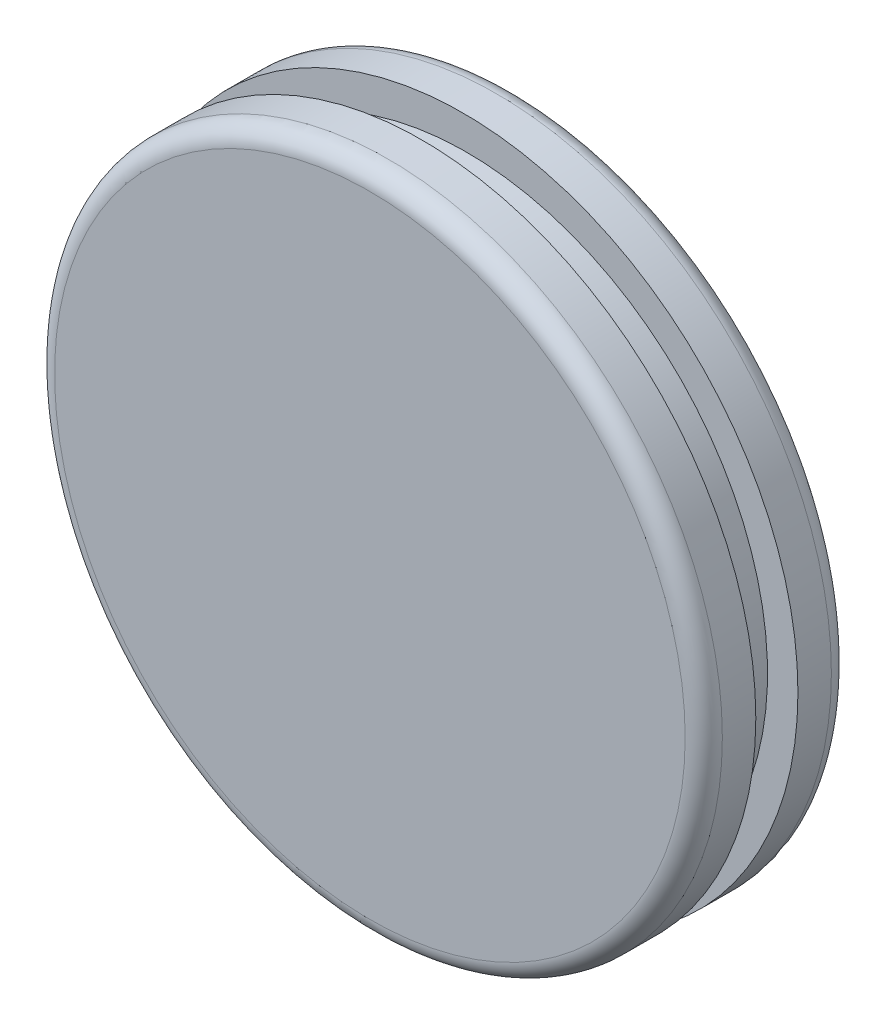
from build123d import *

# Parameters (mm, degrees)
SKETCH1_R           = 22.811957467
BOSS_EXTRUDE1_DEPTH = 3.556
SKETCH2_R           = 20.565315444
BOSS_EXTRUDE2_DEPTH = 3.048
SKETCH3_R           = 22.86
BOSS_EXTRUDE3_DEPTH = 3.556
FILLET2_R           = 1.27
FILLET3_R           = 1.27


with BuildPart() as part:
    # Sketch1 → Boss-Extrude1 (new body)
    with BuildSketch(Plane.XY):
        Circle(SKETCH1_R)
    extrude(amount=BOSS_EXTRUDE1_DEPTH)

    # Sketch2 → Boss-Extrude2 (add)
    with BuildSketch(Plane(origin=(0, 0, 0), x_dir=(-1, 0, 0), z_dir=(0, 0, -1))):
        Circle(SKETCH2_R)
    extrude(amount=BOSS_EXTRUDE2_DEPTH)

    # Sketch3 → Boss-Extrude3 (add)
    with BuildSketch(Plane(origin=(-3.118678077, -2.889960947, -3.048), x_dir=(-1, 0, 0), z_dir=(0, 0, -1))):
        with Locations((-2.900665776, 2.79149385)):
            Circle(SKETCH3_R)
    extrude(amount=BOSS_EXTRUDE3_DEPTH)

    # Fillet2
    fillet2_edges = [part.edges().sort_by_distance(p)[0] for p in [
        (-22.811957467, 0, 3.556),
    ]]
    fillet(fillet2_edges, radius=FILLET2_R)

    # Fillet3
    fillet3_edges = [part.edges().sort_by_distance(p)[0] for p in [
        (22.641987699, -0.098467097, -6.604),
    ]]
    fillet(fillet3_edges, radius=FILLET3_R)


solid = part.part
